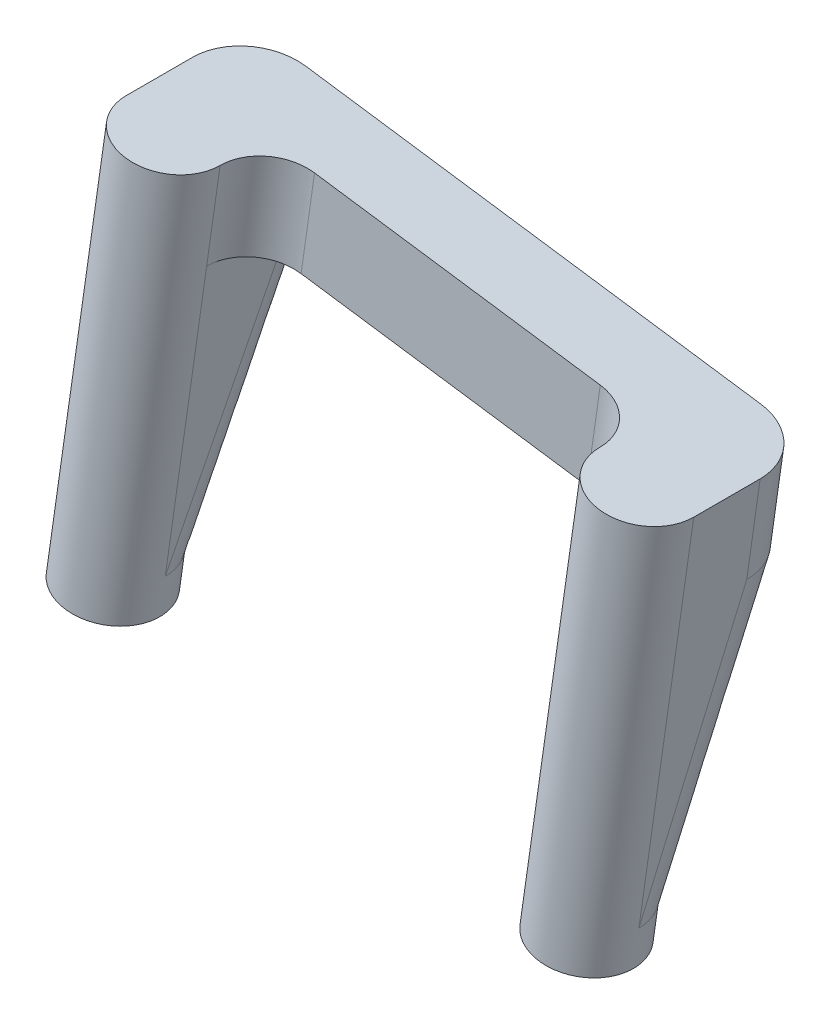
from build123d import *

# Parameters (mm, degrees)
SKETCH1_R             = 2.5
SKETCH1_R_2           = 0.85
BOSS_EXTRUDE1_DEPTH   = 8
BOSS_EXTRUDE1_2_DEPTH = 8
SKETCH2_R             = 2.5
BOSS_EXTRUDE2_DEPTH   = 14.4
BOSS_EXTRUDE3_DEPTH   = 5
BOSS_EXTRUDE4_DEPTH   = 15.4


with BuildPart() as part:
    # Sketch1 → Boss-Extrude1 (new body)
    with BuildSketch(Plane(origin=(21.67087115, 151.425949174, 0), x_dir=(0.989914142, -0.141668597, 0), z_dir=(0.141668597, 0.989914142, 0))):
        with Locations((75.952188142, -57.025881449)):
            Circle(SKETCH1_R)
        with Locations((75.952188142, -57.025881449)):
            Circle(SKETCH1_R_2, mode=Mode.SUBTRACT)
    extrude(amount=BOSS_EXTRUDE1_DEPTH)



with BuildPart() as body_2:
    # Sketch1 → Boss-Extrude1 2 (new body)
    with BuildSketch(Plane(origin=(21.67087115, 151.425949174, 0), x_dir=(0.989914142, -0.141668597, 0), z_dir=(0.141668597, 0.989914142, 0))):
        with Locations((50.752188142, -57.025881449)):
            Circle(SKETCH1_R)
        with Locations((50.752188142, -57.025881449)):
            Circle(SKETCH1_R_2, mode=Mode.SUBTRACT)
    extrude(amount=BOSS_EXTRUDE1_2_DEPTH)


with BuildPart() as part_1:
    add(part.part)

    add(body_2.part)  # Boss-Extrude2 merges body 2
    # Sketch2 → Boss-Extrude2 (add)
    with BuildSketch(Plane(origin=(22.804219929, 159.34526231, 0), x_dir=(0.989914142, -0.141668597, 0), z_dir=(0.141668597, 0.989914142, 0))):
        with Locations((75.952188142, -57.025881449)):
            Circle(SKETCH2_R)
        with Locations((50.752188142, -57.025881449)):
            Circle(SKETCH2_R)
    extrude(amount=BOSS_EXTRUDE2_DEPTH)

    # Sketch3 → Boss-Extrude3 (add)
    with BuildSketch(Plane(origin=(24.84424773, 173.600025954, 0), x_dir=(0.989914142, -0.141668597, 0), z_dir=(0.141668597, 0.989914142, 0))):
        with BuildLine():
            ThreePointArc((53.252188142, -57.025881449), (53.984421189, -55.258114497), (55.752188142, -54.525881449))
            Line((55.752188142, -54.525881449), (70.952188142, -54.525881449))
            ThreePointArc((70.952188142, -54.525881449), (72.719955095, -55.258114497), (73.452188142, -57.025881449))
            ThreePointArc((73.452188142, -57.025881449), (75.952188142, -54.525881449), (78.452188142, -57.025881449))
            Line((78.452188142, -57.025881449), (78.452188142, -53.525881449))
            ThreePointArc((78.452188142, -53.525881449), (77.573508485, -51.404561106), (75.452188142, -50.525881449))
            Line((75.452188142, -50.525881449), (51.252188142, -50.525881449))
            ThreePointArc((51.252188142, -50.525881449), (49.130867798, -51.404561106), (48.252188142, -53.525881449))
            Line((48.252188142, -53.525881449), (48.252188142, -57.025881449))
            Line((48.252188142, -57.025881449), (53.252188142, -57.025881449))
        make_face()
    extrude(amount=-BOSS_EXTRUDE3_DEPTH)

    # Sketch4 → Boss-Extrude4 (add)
    with BuildSketch(Plane(origin=(24.135904744, 168.650455244, 0), x_dir=(0.989914142, -0.141668597, 0), z_dir=(-0.141668597, -0.989914142, 0))):
        with BuildLine():
            Line((53.252188142, 57.025881449), (53.252188142, 52.525881449))
            ThreePointArc((53.252188142, 52.525881449), (52.666401704, 51.111667887), (51.252188142, 50.525881449))
            ThreePointArc((51.252188142, 50.525881449), (49.130867798, 51.404561106), (48.252188142, 53.525881449))
            Line((48.252188142, 53.525881449), (48.252188142, 57.025881449))
            ThreePointArc((48.252188142, 57.025881449), (50.752188142, 54.525881449), (53.252188142, 57.025881449))
        make_face()
        with BuildLine():
            Line((73.452188142, 57.025881449), (73.452188142, 52.525881449))
            ThreePointArc((73.452188142, 52.525881449), (74.037974579, 51.111667887), (75.452188142, 50.525881449))
            ThreePointArc((75.452188142, 50.525881449), (77.573508485, 51.404561106), (78.452188142, 53.525881449))
            Line((78.452188142, 53.525881449), (78.452188142, 57.025881449))
            ThreePointArc((78.452188142, 57.025881449), (75.952188142, 54.525881449), (73.452188142, 57.025881449))
        make_face()
    extrude(amount=BOSS_EXTRUDE4_DEPTH)

    # Sketch9 → Cut-Loft7 section 0
    with BuildSketch(Plane(origin=(21.954208345, 153.405777458, 0), x_dir=(0.989914142, -0.141668597, 0), z_dir=(-0.141668597, -0.989914142, 0))):
        with BuildLine():
            Line((48.252188142, 57.025881449), (43.252188142, 57.025881449))
            ThreePointArc((43.252188142, 57.025881449), (45.448887283, 51.722580591), (50.752188142, 49.525881449))
            ThreePointArc((50.752188142, 49.525881449), (56.055489001, 51.722580591), (58.252188142, 57.025881449))
            Line((58.252188142, 57.025881449), (53.252188142, 57.025881449))
            ThreePointArc((53.252188142, 57.025881449), (52.519955095, 55.258114497), (50.752188142, 54.525881449))
            ThreePointArc((50.752188142, 54.525881449), (48.984421189, 55.258114497), (48.252188142, 57.025881449))
        make_face()
    # Sketch8 → Cut-Loft7 section 1
    with BuildSketch(Plane(origin=(24.135904744, 168.650455244, 0), x_dir=(0.989914142, -0.141668597, 0), z_dir=(-0.141668597, -0.989914142, 0))):
        with BuildLine():
            Line((48.252188142, 53.525881449), (45.252188142, 53.525881449))
            ThreePointArc((45.252188142, 53.525881449), (47.009547455, 49.283240762), (51.252188142, 47.525881449))
            ThreePointArc((51.252188142, 47.525881449), (54.787722048, 48.990347544), (56.252188142, 52.525881449))
            Line((56.252188142, 52.525881449), (53.252188142, 52.525881449))
            ThreePointArc((53.252188142, 52.525881449), (52.666401704, 51.111667887), (51.252188142, 50.525881449))
            ThreePointArc((51.252188142, 50.525881449), (49.130867798, 51.404561106), (48.252188142, 53.525881449))
        make_face()
    loft(mode=Mode.SUBTRACT)

    # Sketch9_3 → Cut-Loft8 section 0
    with BuildSketch(Plane(origin=(21.954208345, 153.405777458, 0), x_dir=(0.989914142, -0.141668597, 0), z_dir=(-0.141668597, -0.989914142, 0))):
        with BuildLine():
            Line((73.452188142, 57.025881449), (68.452188142, 57.025881449))
            ThreePointArc((68.452188142, 57.025881449), (70.648887283, 51.722580591), (75.952188142, 49.525881449))
            ThreePointArc((75.952188142, 49.525881449), (81.255489001, 51.722580591), (83.452188142, 57.025881449))
            Line((83.452188142, 57.025881449), (78.452188142, 57.025881449))
            ThreePointArc((78.452188142, 57.025881449), (77.719955095, 55.258114497), (75.952188142, 54.525881449))
            ThreePointArc((75.952188142, 54.525881449), (74.184421189, 55.258114497), (73.452188142, 57.025881449))
        make_face()
    # Sketch8_8 → Cut-Loft8 section 1
    with BuildSketch(Plane(origin=(24.135904744, 168.650455244, 0), x_dir=(0.989914142, -0.141668597, 0), z_dir=(-0.141668597, -0.989914142, 0))):
        with BuildLine():
            Line((73.452188142, 52.525881449), (70.452188142, 52.525881449))
            ThreePointArc((70.452188142, 52.525881449), (71.916654236, 48.990347544), (75.452188142, 47.525881449))
            ThreePointArc((75.452188142, 47.525881449), (79.694828829, 49.283240762), (81.452188142, 53.525881449))
            Line((81.452188142, 53.525881449), (78.452188142, 53.525881449))
            ThreePointArc((78.452188142, 53.525881449), (77.573508485, 51.404561106), (75.452188142, 50.525881449))
            ThreePointArc((75.452188142, 50.525881449), (74.037974579, 51.111667887), (73.452188142, 52.525881449))
        make_face()
    loft(mode=Mode.SUBTRACT)


solid = part_1.part
